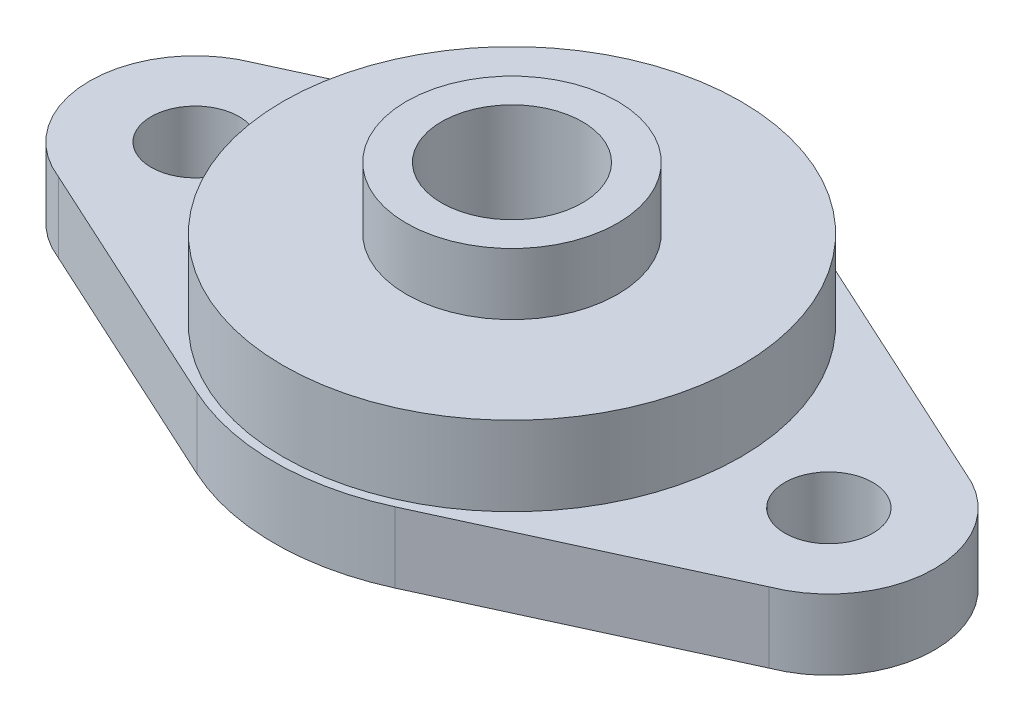
from build123d import *

# Parameters (mm, degrees)
SKETCH1_R           = 2.5
SKETCH1_R_2         = 4
BOSS_EXTRUDE1_DEPTH = 4
SKETCH2_R           = 13
SKETCH2_R_2         = 4
BOSS_EXTRUDE2_DEPTH = 4.5
SKETCH3_R           = 6
SKETCH3_R_2         = 4
BOSS_EXTRUDE3_DEPTH = 3.5


with BuildPart() as part:
    # Sketch1 → Boss-Extrude1 (new body)
    with BuildSketch(Plane(origin=(0, 0, 0), x_dir=(1, 0, 0), z_dir=(0, 1, 0))):
        with BuildLine():
            Line((-20.189639751, 5.586186334), (-5.632256707, 12.268972426))
            ThreePointArc((-5.632256707, 12.268972426), (0, 13.5), (5.632256707, 12.268972426))
            Line((5.632256707, 12.268972426), (20.189639751, 5.586186334))
            ThreePointArc((20.189639751, 5.586186334), (24, 0), (20.189639751, -5.586186334))
            Line((20.189639751, -5.586186334), (5.632256707, -12.268972426))
            ThreePointArc((5.632256707, -12.268972426), (0, -13.5), (-5.632256707, -12.268972426))
            Line((-5.632256707, -12.268972426), (-20.189639751, -5.586186334))
            ThreePointArc((-20.189639751, -5.586186334), (-24, 0), (-20.189639751, 5.586186334))
        make_face()
        with Locations((18, 0)):
            Circle(SKETCH1_R, mode=Mode.SUBTRACT)
        with Locations((-18, 0)):
            Circle(SKETCH1_R, mode=Mode.SUBTRACT)
        Circle(SKETCH1_R_2, mode=Mode.SUBTRACT)
    extrude(amount=BOSS_EXTRUDE1_DEPTH)

    # Sketch2 → Boss-Extrude2 (add)
    with BuildSketch(Plane(origin=(0, 4, 0), x_dir=(1, 0, 0), z_dir=(0, 1, 0))):
        Circle(SKETCH2_R)
        Circle(SKETCH2_R_2, mode=Mode.SUBTRACT)
    extrude(amount=BOSS_EXTRUDE2_DEPTH)

    # Sketch3 → Boss-Extrude3 (add)
    with BuildSketch(Plane(origin=(0, 8.5, 0), x_dir=(1, 0, 0), z_dir=(0, 1, 0))):
        Circle(SKETCH3_R)
        Circle(SKETCH3_R_2, mode=Mode.SUBTRACT)
    extrude(amount=BOSS_EXTRUDE3_DEPTH)


solid = part.part
